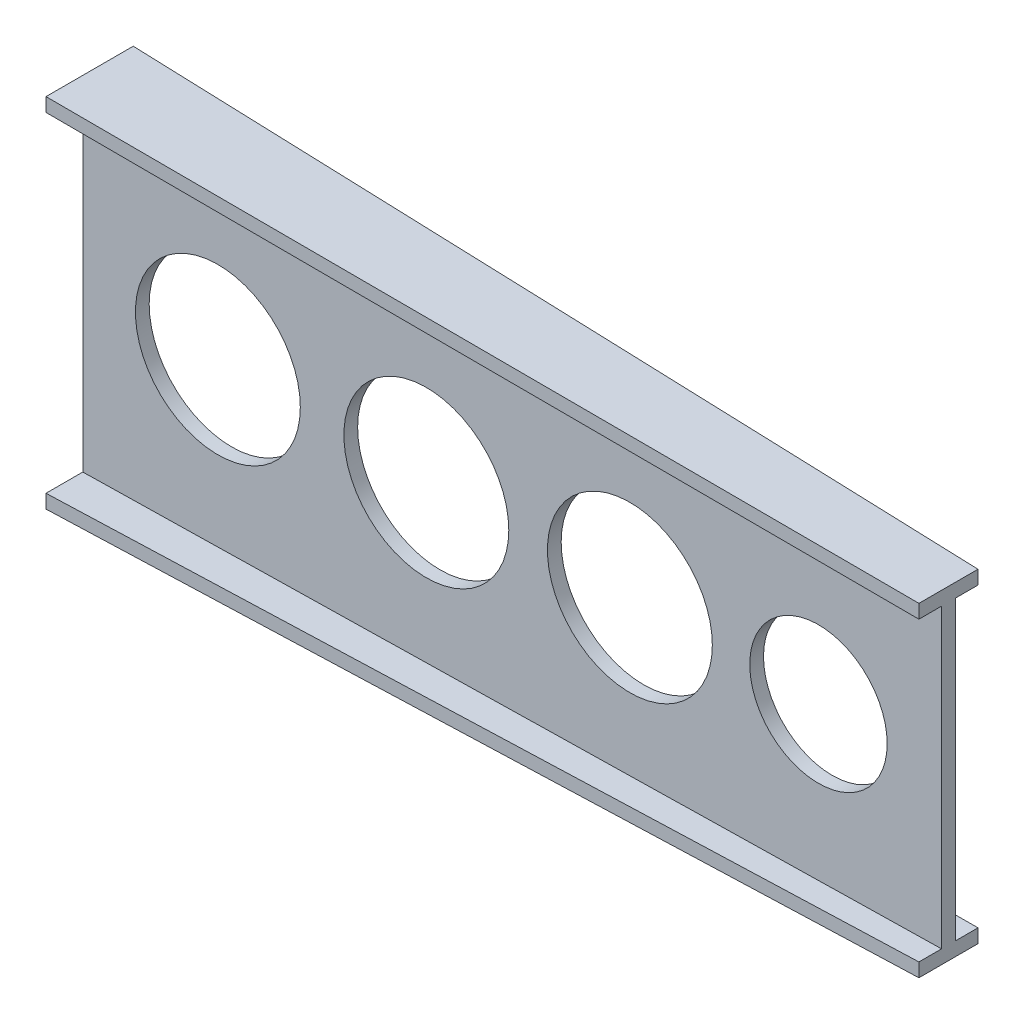
from build123d import *

# Parameters (mm, degrees)
SKETCH6_R          = 120
SKETCH6_R_2        = 100
CUT_EXTRUDE1_DEPTH = 74.5000001


with BuildPart() as part:
    # Sketch1 → Loft l3 section 0
    with BuildSketch(Plane(origin=(0, 0, 0), x_dir=(0, 0, -1), z_dir=(1, 0, 0))):
        Polygon((-73.5, 260), (53.5, 260), (53.5, 240), (0, 240), (0, -240), (53.5, -240), (53.5, -260), (-73.5, -260), (-73.5, -240), (-20, -240), (-20, 240), (-73.5, 240), align=None)
    # Sketch4 → Loft l3 section 1
    with BuildSketch(Plane(origin=(1250, 0, -1000), x_dir=(0, 0, 1), z_dir=(-1, 0, 0))):
        Polygon((967, 236), (1053, 236), (1053, 216), (1020, 216), (1020, -216), (1053, -216), (1053, -236), (967, -236), (967, -216), (1000, -216), (1000, 216), (967, 216), align=None)
    loft()

    # Sketch6 → Cut-Extrude1 (cut, through all)
    with BuildSketch(Plane.XY.offset(20)):
        with Locations((196.664397563, 0)):
            Circle(SKETCH6_R)
        with Locations((500.077852957, -3.284154434)):
            Circle(SKETCH6_R)
        with Locations((796.32876443, 0)):
            Circle(SKETCH6_R)
        with Locations((1070.806505034, 2.998831576)):
            Circle(SKETCH6_R_2)
    extrude(amount=-CUT_EXTRUDE1_DEPTH, mode=Mode.SUBTRACT)


solid = part.part
